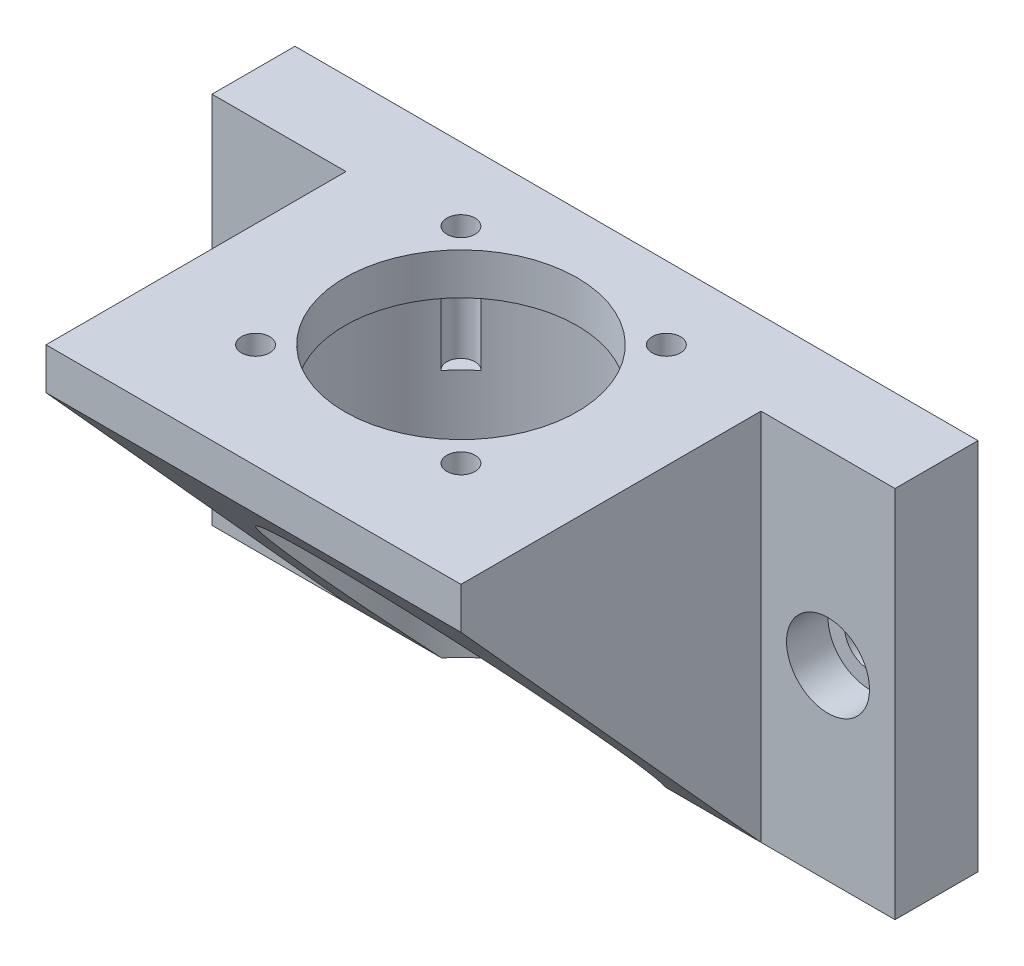
from build123d import *

# Parameters (mm, degrees)
EXTRUDE_1_DEPTH          = 45
SKETCH_2_R               = 17.5
CUT_EXTRUDE_1_DEPTH      = 40
SKETCH_3_R               = 14
CUT_EXTRUDE_2_DEPTH      = 63.596505494
CUT_EXTRUDE_3_DEPTH      = 10
CUT_EXTRUDE_3_DEPTH_BACK = 14
SKETCH_4_R               = 1.7
SKETCH_5_R               = 3
CUT_EXTRUDE_4_DEPTH      = 71.888257138
SKETCH_6_R               = 5
CUT_EXTRUDE_5_DEPTH      = 5
CUT_EXTRUDE_6_DEPTH      = 84.820179551


with BuildPart() as part:
    # Эскиз1 → Бобышка-Вытянуть1 (new body)
    with BuildSketch(Plane(origin=(0, 0, 0), x_dir=(1, 0, 0), z_dir=(0, 1, 0))):
        Polygon((-21.15, 21.15), (21.15, 21.15), (41.15, 21.15), (41.15, 11.15), (25, 11.15), (25, -25), (-25, -25), (-25, 11.15), (-41.15, 11.15), (-41.15, 21.15), align=None)
    extrude(amount=EXTRUDE_1_DEPTH)

    # Эскиз2 → Вырез-Вытянуть1 (cut)
    with BuildSketch(Plane.XZ):
        with Locations(Location((0, 0, 0), (0, 0, 270))):
            Circle(SKETCH_2_R)
    extrude(amount=-CUT_EXTRUDE_1_DEPTH, mode=Mode.SUBTRACT)

    # Эскиз3 → Вырез-Вытянуть2 (cut, through all)
    with BuildSketch(Plane.XZ.offset(-40)):
        with Locations(Location((0, 0, 0), (0, 0, 270))):
            Circle(SKETCH_3_R)
    extrude(amount=-CUT_EXTRUDE_2_DEPTH, mode=Mode.SUBTRACT)

    # Эскиз4 → Вырез-Вытянуть3 (cut, two sides: drawn at the far end of the back side and taken through both)
    with BuildSketch(Plane.XZ.offset(-40).offset(-CUT_EXTRUDE_3_DEPTH_BACK)):
        with Locations(Location((-12.374368671, -12.374368671, 0), (0, 0, 270))):
            Circle(SKETCH_4_R)
        with Locations(Location((12.374368671, -12.374368671, 0), (0, 0, 270))):
            Circle(SKETCH_4_R)
        with Locations(Location((12.374368671, 12.374368671, 0), (0, 0, 270))):
            Circle(SKETCH_4_R)
        with Locations(Location((-12.374368671, 12.374368671, 0), (0, 0, 270))):
            Circle(SKETCH_4_R)
    extrude(amount=CUT_EXTRUDE_3_DEPTH + CUT_EXTRUDE_3_DEPTH_BACK, mode=Mode.SUBTRACT)

    # Эскиз5 → Вырез-Вытянуть4 (cut, through all)
    with BuildSketch(Plane.XY.offset(-11.15)):
        with Locations((-33.075, 22.5)):
            Circle(SKETCH_5_R)
        with Locations((33.075, 22.5)):
            Circle(SKETCH_5_R)
    extrude(amount=-CUT_EXTRUDE_4_DEPTH, mode=Mode.SUBTRACT)

    # Эскиз6 → Вырез-Вытянуть5 (cut)
    with BuildSketch(Plane.XY.offset(-11.15)):
        with Locations((-33.075, 22.5)):
            Circle(SKETCH_6_R)
        with Locations((33.075, 22.5)):
            Circle(SKETCH_6_R)
    extrude(amount=-CUT_EXTRUDE_5_DEPTH, mode=Mode.SUBTRACT)

    # Эскиз7 → Вырез-Вытянуть6 (cut, through all)
    with BuildSketch(Plane(origin=(25, 0, 0), x_dir=(0, 0, -1), z_dir=(1, 0, 0))):
        Polygon((-25, 40), (11.15, 0), (-25, 0), align=None)
    extrude(amount=-CUT_EXTRUDE_6_DEPTH, mode=Mode.SUBTRACT)


solid = part.part
